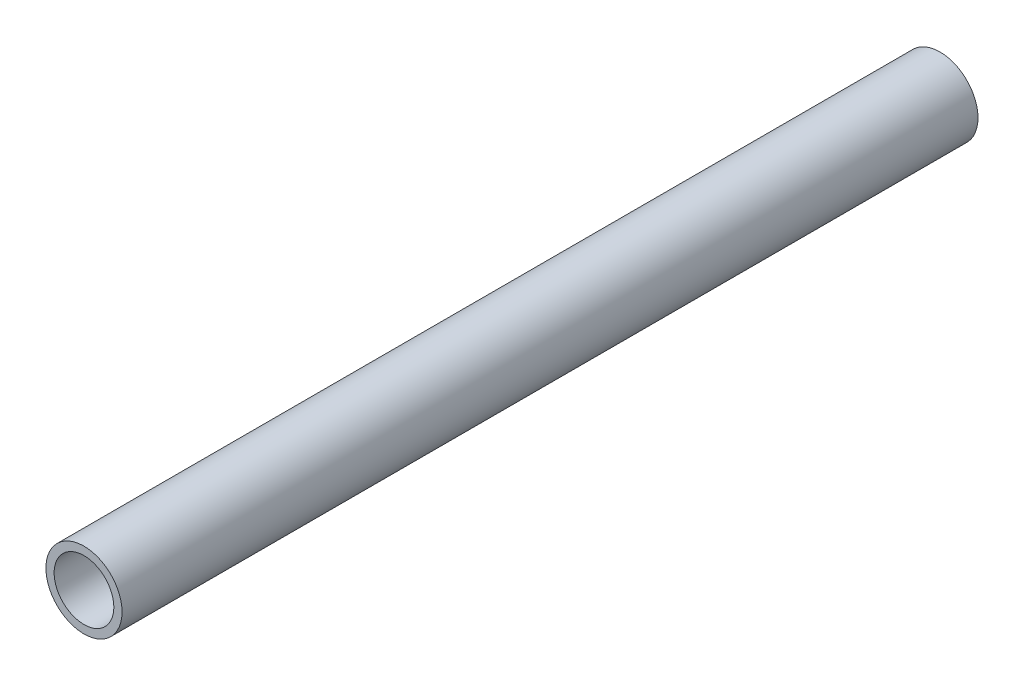
from build123d import *

# Parameters (mm, degrees)
SKETCH1_R           = 13.335
SKETCH1_R_2         = 10.4648
EXTRUDE_THIN1_DEPTH = 150


with BuildPart() as part:
    # Sketch1 → Extrude-Thin1 (new body, symmetric)
    with BuildSketch(Plane.XY):
        Circle(SKETCH1_R)
        Circle(SKETCH1_R_2, mode=Mode.SUBTRACT)
    extrude(amount=EXTRUDE_THIN1_DEPTH, both=True)


solid = part.part
